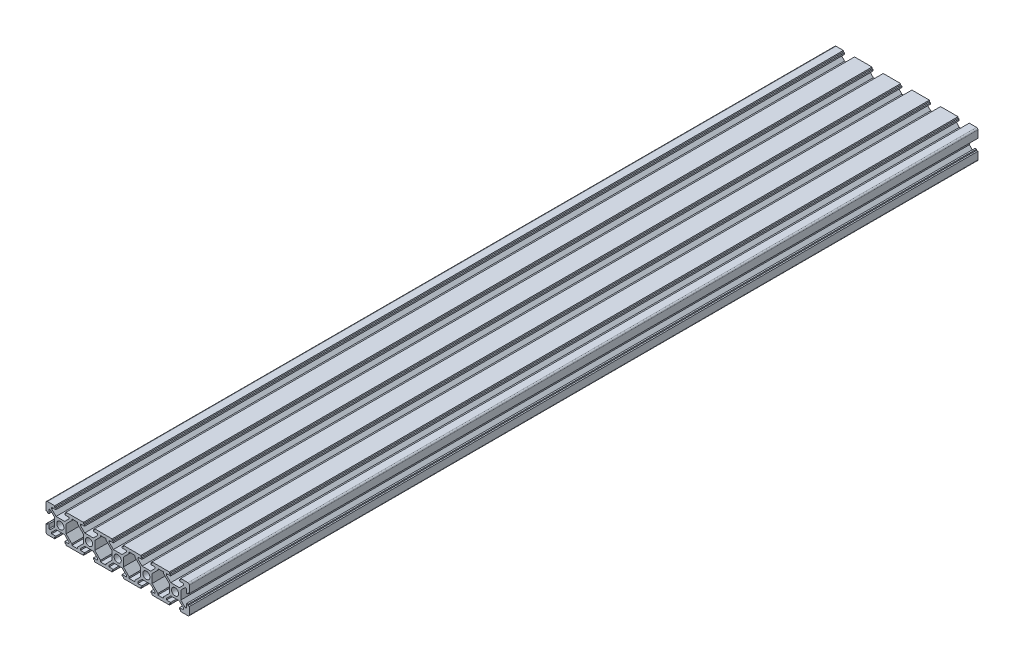
from build123d import *

# Parameters (mm, degrees)
SKETCH_1_R      = 2.5
EXTRUDE_1_DEPTH = 550
FILLET_1_R      = 1


with BuildPart() as part:
    # Sketch 1 → Extrude 1 (new body)
    with BuildSketch(Plane.XY):
        Polygon((-20, 10), (-13.9, 10), (-13.9, 8.996845012), (-13.1, 8.996845012), (-13.1, 8), (-16.004631122, 8), (-16.004631122, 6.994580616), (-13.010050506, 4), (-6.989949494, 4), (-3.995368878, 6.994580616), (-3.995368878, 8), (-6.9, 8), (-6.9, 8.996845012), (-6.1, 8.996845012), (-6.1, 10), (6.1, 10), (6.1, 8.996845012), (6.9, 8.996845012), (6.9, 8), (3.995368878, 8), (3.995368878, 6.994580616), (6.989949494, 4), (13.010050506, 4), (16.004631122, 6.994580616), (16.004631122, 8), (13.1, 8), (13.1, 8.996845012), (13.9, 8.996845012), (13.9, 10), (26.1, 10), (26.1, 8.996845012), (26.9, 8.996845012), (26.9, 8), (23.995368878, 8), (23.995368878, 6.994580616), (26.989949494, 4), (33.010050506, 4), (36.004631122, 6.994580616), (36.004631122, 8), (33.1, 8), (33.1, 8.996845012), (33.9, 8.996845012), (33.9, 10), (46.1, 10), (46.1, 8.996845012), (46.9, 8.996845012), (46.9, 8), (43.995368878, 8), (43.995368878, 6.994580616), (46.989949494, 4), (53.010050506, 4), (56.004631122, 6.994580616), (56.004631122, 8), (53.1, 8), (53.1, 8.996845012), (53.9, 8.996845012), (53.9, 10), (66.1, 10), (66.1, 8.996845012), (66.9, 8.996845012), (66.9, 8), (63.995368878, 8), (63.995368878, 6.994580616), (66.989949494, 4), (73.010050506, 4), (76.004631122, 6.994580616), (76.004631122, 8), (73.1, 8), (73.1, 8.996845012), (73.9, 8.996845012), (73.9, 10), (80, 10), (80, 3.9), (78.996845012, 3.9), (78.996845012, 3.09747601), (78, 3.09747601), (78, 6), (76.989949494, 6), (74, 3.010050506), (74, -3.010050506), (76.989949494, -6), (78, -6), (78, -3.09747601), (78.996845012, -3.09747601), (78.996845012, -3.9), (80, -3.9), (80, -10), (73.9, -10), (73.9, -8.996845012), (73.1, -8.996845012), (73.1, -8), (76.004631122, -8), (76.004631122, -6.994580616), (73.010050506, -4), (66.989949494, -4), (63.995368878, -6.994580616), (63.995368878, -8), (66.9, -8), (66.9, -8.996845012), (66.1, -8.996845012), (66.1, -10), (53.9, -10), (53.9, -8.996845012), (53.1, -8.996845012), (53.1, -8), (56.004631122, -8), (56.004631122, -6.994580616), (53.010050506, -4), (46.989949494, -4), (43.995368878, -6.994580616), (43.995368878, -8), (46.9, -8), (46.9, -8.996845012), (46.1, -8.996845012), (46.1, -10), (33.9, -10), (33.9, -8.996845012), (33.1, -8.996845012), (33.1, -8), (36.004631122, -8), (36.004631122, -6.994580616), (33.010050506, -4), (26.989949494, -4), (23.995368878, -6.994580616), (23.995368878, -8), (26.9, -8), (26.9, -8.996845012), (26.1, -8.996845012), (26.1, -10), (13.9, -10), (13.9, -8.996845012), (13.1, -8.996845012), (13.1, -8), (16.004631122, -8), (16.004631122, -6.994580616), (13.010050506, -4), (6.989949494, -4), (3.995368878, -6.994580616), (3.995368878, -8), (6.9, -8), (6.9, -8.996845012), (6.1, -8.996845012), (6.1, -10), (-6.1, -10), (-6.1, -8.996845012), (-6.9, -8.996845012), (-6.9, -8), (-3.995368878, -8), (-3.995368878, -6.994580616), (-6.989949494, -4), (-13.010050506, -4), (-16.004631122, -6.994580616), (-16.004631122, -8), (-13.1, -8), (-13.1, -8.996845012), (-13.9, -8.996845012), (-13.9, -10), (-20, -10), (-20, -3.9), (-18.996845012, -3.9), (-18.996845012, -3.09747601), (-18, -3.09747601), (-18, -6), (-16.989949494, -6), (-14, -3.010050506), (-14, 3.010050506), (-16.989949494, 6), (-18, 6), (-18, 3.09747601), (-18.996845012, 3.09747601), (-18.996845012, 3.9), (-20, 3.9), align=None)
        with Locations((-10, 0)):
            Circle(SKETCH_1_R, mode=Mode.SUBTRACT)
        with Locations((10, 0)):
            Circle(SKETCH_1_R, mode=Mode.SUBTRACT)
        with Locations((30, 0)):
            Circle(SKETCH_1_R, mode=Mode.SUBTRACT)
        with Locations((50, 0)):
            Circle(SKETCH_1_R, mode=Mode.SUBTRACT)
        with Locations((70, 0)):
            Circle(SKETCH_1_R, mode=Mode.SUBTRACT)
        Polygon((22.015469891, 8), (17.984530109, 8), (17.984530109, 6.994580616), (14, 3.010050506), (14, -3.010050506), (17.984530109, -6.994580616), (17.984530109, -8), (22.015469891, -8), (22.015469891, -6.994580616), (26, -3.010050506), (26, 3.010050506), (22.015469891, 6.994580616), align=None, mode=Mode.SUBTRACT)
        Polygon((42.015469891, 8), (37.984530109, 8), (37.984530109, 6.994580616), (34, 3.010050506), (34, -3.010050506), (37.984530109, -6.994580616), (37.984530109, -8), (42.015469891, -8), (42.015469891, -6.994580616), (46, -3.010050506), (46, 3.010050506), (42.015469891, 6.994580616), align=None, mode=Mode.SUBTRACT)
        Polygon((62.015469891, 8), (57.984530109, 8), (57.984530109, 6.994580616), (54, 3.010050506), (54, -3.010050506), (57.984530109, -6.994580616), (57.984530109, -8), (62.015469891, -8), (62.015469891, -6.994580616), (66, -3.010050506), (66, 3.010050506), (62.015469891, 6.994580616), align=None, mode=Mode.SUBTRACT)
        Polygon((2.015469891, -8), (2.015469891, -6.994580616), (6, -3.010050506), (6, 3.010050506), (2.015469891, 6.994580616), (2.015469891, 8), (-2.015469891, 8), (-2.015469891, 6.994580616), (-6, 3.010050506), (-6, -3.010050506), (-2.015469891, -6.994580616), (-2.015469891, -8), align=None, mode=Mode.SUBTRACT)
    extrude(amount=EXTRUDE_1_DEPTH)

    # Fillet 1
    fillet_1_edges = [part.edges().sort_by_distance(p)[0] for p in [
        (80, 10, 275),
        (80, -10, 275),
        (-20, -10, 275),
        (-20, 10, 275),
    ]]
    fillet(fillet_1_edges, radius=FILLET_1_R)


solid = part.part
